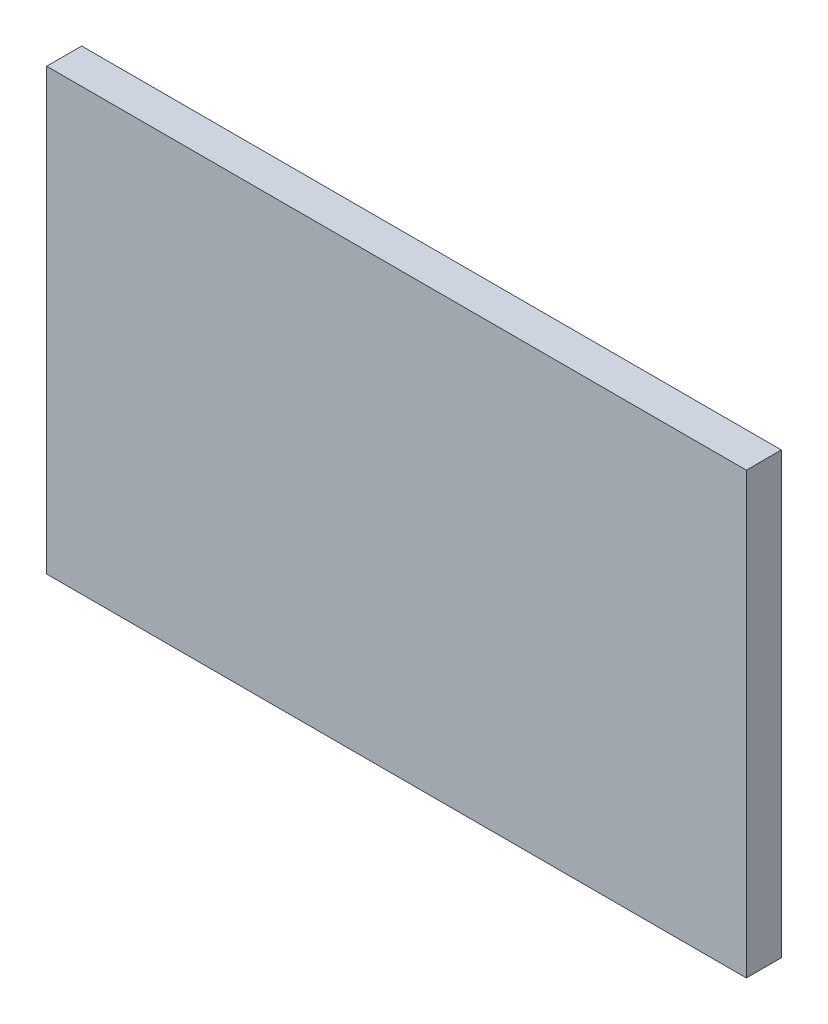
from build123d import *

# Parameters (mm, degrees)
SKETCH1_W           = 28
SKETCH1_H           = 17.6
BOSS_EXTRUDE1_DEPTH = 1.4


with BuildPart() as part:
    # Sketch1 → Boss-Extrude1 (new body)
    with BuildSketch(Plane.XY):
        Rectangle(SKETCH1_W, SKETCH1_H)
    extrude(amount=BOSS_EXTRUDE1_DEPTH)


solid = part.part
